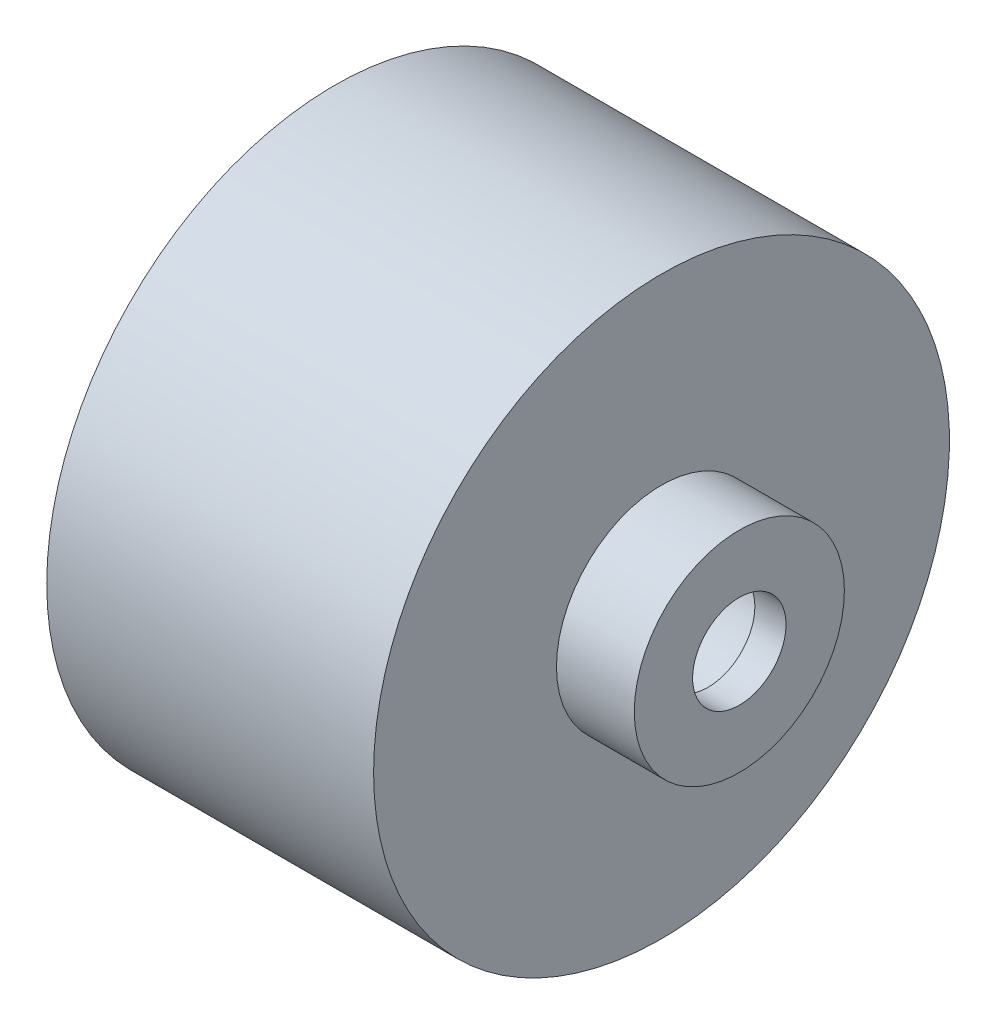
from build123d import *

# Parameters (mm, degrees)
SKETCH1_R           = 18.5
BOSS_EXTRUDE1_DEPTH = 21
SKETCH2_R           = 6.75
BOSS_EXTRUDE2_DEPTH = 5
SHELL1_T            = -2
SKETCH3_R           = 3
CUT_EXTRUDE1_DEPTH  = 5


with BuildPart() as part:
    # Sketch1 → Boss-Extrude1 (new body)
    with BuildSketch(Plane(origin=(0, 0, 0), x_dir=(0, 0, -1), z_dir=(1, 0, 0))):
        Circle(SKETCH1_R)
    extrude(amount=BOSS_EXTRUDE1_DEPTH)

    # Sketch2 → Boss-Extrude2 (add)
    with BuildSketch(Plane(origin=(21, 0, 0), x_dir=(0, 0, -1), z_dir=(1, 0, 0))):
        Circle(SKETCH2_R)
    extrude(amount=BOSS_EXTRUDE2_DEPTH)

    # Shell1
    shell1_openings = [part.faces().sort_by_distance(p)[0] for p in [
        (0, 0, 0),
    ]]
    offset(amount=SHELL1_T, openings=shell1_openings, kind=Kind.INTERSECTION)

    # Sketch3 → Cut-Extrude1 (cut)
    with BuildSketch(Plane(origin=(26, 0, 0), x_dir=(0, 0, -1), z_dir=(1, 0, 0))):
        Circle(SKETCH3_R)
    extrude(amount=-CUT_EXTRUDE1_DEPTH, mode=Mode.SUBTRACT)


solid = part.part
